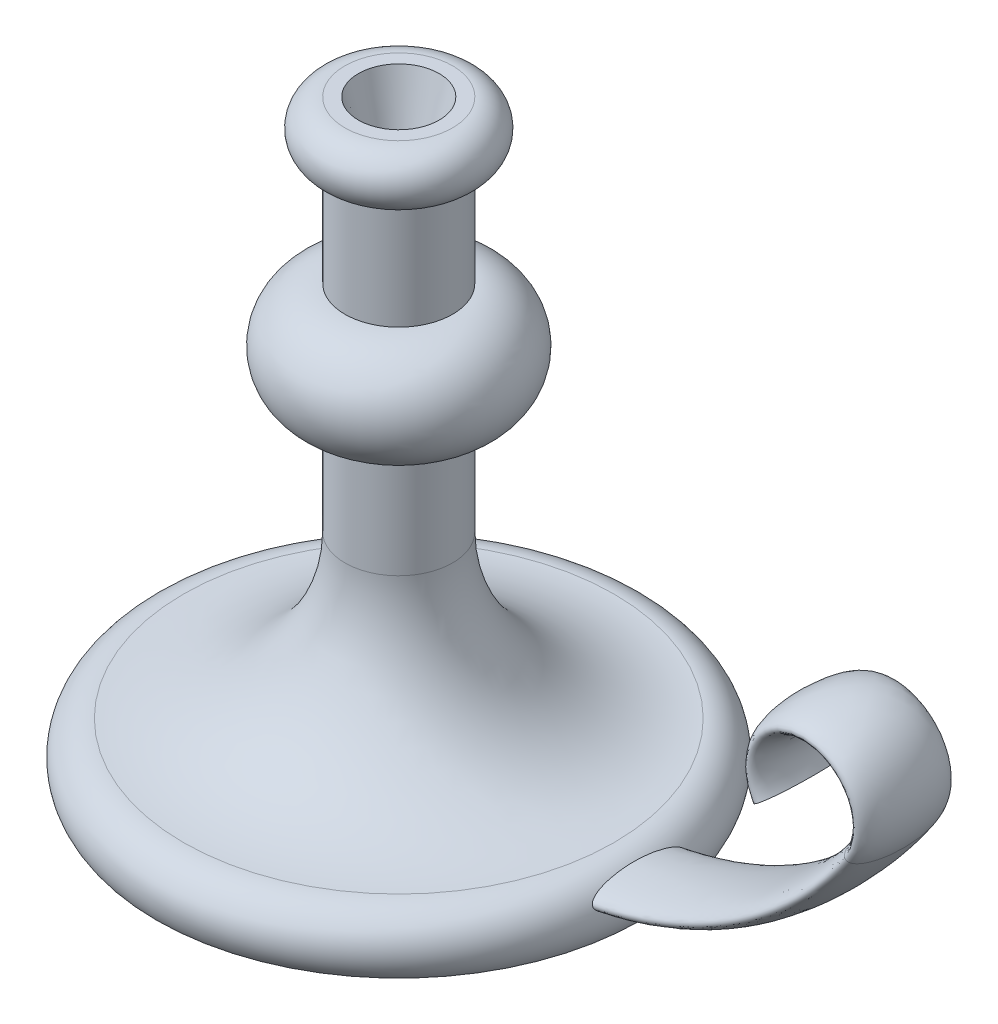
from build123d import *

# Parameters (mm, degrees)
SKETCH3_RX         = 17.5
SKETCH3_RY         = 5
SKETCH4_R          = 15
CUT_EXTRUDE1_DEPTH = 25
CUT_EXTRUDE1_DRAFT = -15


with BuildPart() as part:
    # Sketch1 → Revolve1 (revolve)
    with BuildSketch(Plane.XY):
        with BuildLine():
            Line((20, 68.5), (0, 68.5))
            Line((0, 68.5), (0, -151.5))
            Line((0, -151.5), (90, -151.5))
            ThreePointArc((90, -151.5), (91.180339887, -138.409830056), (80, -131.5))
            ThreePointArc((80, -131.5), (37.573593129, -113.926406871), (20, -71.5))
            Line((20, -71.5), (20, -31.5))
            ThreePointArc((20, -31.5), (40, -11.5), (20, 8.5))
            Line((20, 8.5), (20, 48.5))
            ThreePointArc((20, 48.5), (30, 58.5), (20, 68.5))
        make_face()
    revolve(axis=Axis((0, 68.5, 0), (0, -1, 0)))

    # Sweep1: sweep along a path in Sketch2
    with BuildLine(Plane.XY) as sweep1_path:
        Line((0, -141.5), (60, -141.5))
        ThreePointArc((60, -141.5), (129.821200219, -124.259180474), (183.592070943, -76.5))
        ThreePointArc((183.592070943, -76.5), (167.816896383, -45.179052745), (149.877884577, -75.312916168))
    # Sketch3 → Sweep1 (sweep)
    with BuildSketch(Plane(origin=(0, 0, 0), x_dir=(0, 0, -1), z_dir=(1, 0, 0))):
        with Locations((0, -141.5)):
            Ellipse(SKETCH3_RX, SKETCH3_RY)
    sweep(path=sweep1_path.line)


with BuildPart() as cut_extrude1_tool:
    # Sketch4 → Cut-Extrude1 (with draft: the straight prism first)
    with BuildSketch(Plane(origin=(0, 68.5, 0), x_dir=(1, 0, 0), z_dir=(0, 1, 0))):
        Circle(SKETCH4_R)
    extrude(amount=-CUT_EXTRUDE1_DEPTH)
    # Cut-Extrude1: the draft: its side faces are tilted about the plane it starts from
    cut_extrude1_sides = [cut_extrude1_tool.faces().sort_by_distance(p)[0] for p in [
        (-15, 56, 0),
    ]]
    draft(cut_extrude1_sides, Plane(origin=(0, 68.5, 0), x_dir=(1, 0, 0), z_dir=(0, 1, 0)), CUT_EXTRUDE1_DRAFT)


with BuildPart() as part_1:
    add(part.part)

    # Cut-Extrude1: cut by cut_extrude1_tool
    add(cut_extrude1_tool.part, mode=Mode.SUBTRACT)


solid = part_1.part
